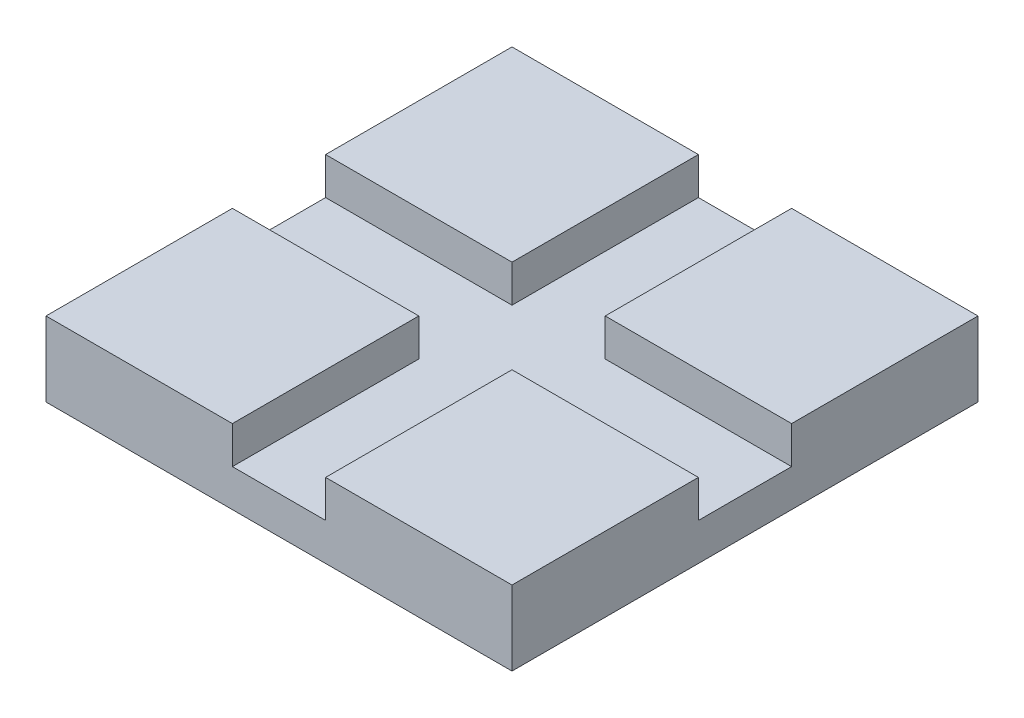
from build123d import *

# Parameters (mm, degrees)
SKETCH1_W           = 25
SKETCH1_H           = 25
BOSS_EXTRUDE1_DEPTH = 2
SKETCH2_W           = 10
SKETCH2_H           = 10
BOSS_EXTRUDE4_DEPTH = 2


with BuildPart() as part:
    # Sketch1 → Boss-Extrude1 (new body)
    with BuildSketch(Plane(origin=(0, 0, 0), x_dir=(1, 0, 0), z_dir=(0, 1, 0))):
        Rectangle(SKETCH1_W, SKETCH1_H)
    extrude(amount=BOSS_EXTRUDE1_DEPTH)

    # Sketch2 → Boss-Extrude4 (add)
    with BuildSketch(Plane(origin=(0, 2, 0), x_dir=(1, 0, 0), z_dir=(0, 1, 0))):
        with Locations((7.5, -7.5)):
            Rectangle(SKETCH2_W, SKETCH2_H)
        with Locations((-7.5, -7.5)):
            Rectangle(SKETCH2_W, SKETCH2_H)
        with Locations((-7.5, 7.5)):
            Rectangle(SKETCH2_W, SKETCH2_H)
        with Locations((7.5, 7.5)):
            Rectangle(SKETCH2_W, SKETCH2_H)
    extrude(amount=BOSS_EXTRUDE4_DEPTH)


solid = part.part
